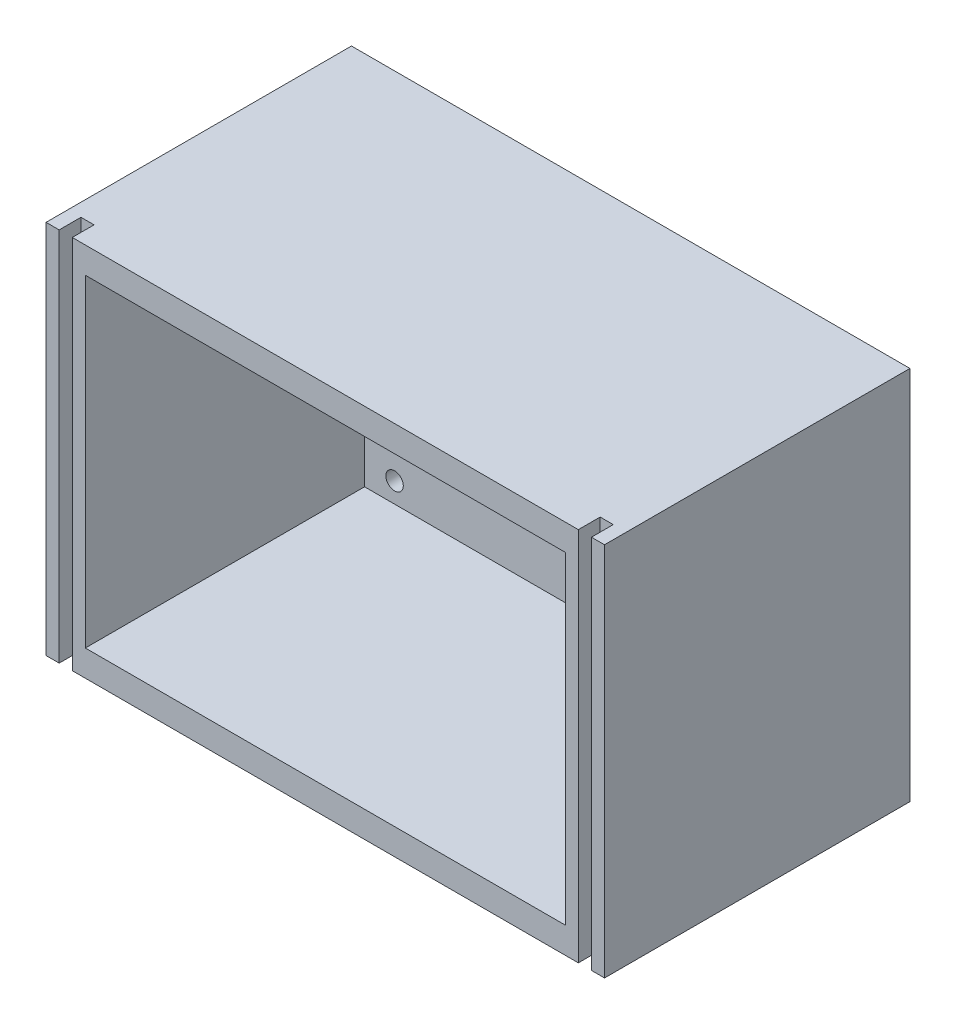
from build123d import *

# Parameters (mm, degrees)
SKETCH_1_W         = 3
SKETCH_1_H         = 86
EXTRUDE_10_DEPTH   = 70
SKETCH_1_W_2       = 116
SKETCH_1_W_3       = 110
SKETCH_1_H_2       = 74
EXTRUDE_10_2_DEPTH = 70
EXTRUDE_10_3_DEPTH = 70
EXTRUDE_11_DEPTH   = 65
SKETCH_1_12_W      = 110
SKETCH_1_12_H      = 74
SKETCH_1_12_R      = 2
EXTRUDE_12_DEPTH   = 6


with BuildPart() as part:
    # Эскиз1 → Бобышка-Вытянуть10 (new body)
    with BuildSketch(Plane.XY):
        with Locations((-60.077319588, 1.278350515)):
            Rectangle(SKETCH_1_W, SKETCH_1_H)
    extrude(amount=EXTRUDE_10_DEPTH)



with BuildPart() as body_2:
    # Эскиз1 → Extrude 10 2 (new body)
    with BuildSketch(Plane.XY):
        with Locations((2.422680412, 1.278350515)):
            Rectangle(SKETCH_1_W_2, SKETCH_1_H)
        with Locations((2.422680412, 1.278350515)):
            Rectangle(SKETCH_1_W_3, SKETCH_1_H_2, mode=Mode.SUBTRACT)
    extrude(amount=EXTRUDE_10_2_DEPTH)


with BuildPart() as body_3:
    # Эскиз1 → Extrude 10 3 (new body)
    with BuildSketch(Plane.XY):
        with Locations((64.922680412, 1.278350515)):
            Rectangle(SKETCH_1_W, SKETCH_1_H)
    extrude(amount=EXTRUDE_10_3_DEPTH)


with BuildPart() as part_1:
    add(part.part)

    add(body_2.part)  # Бобышка-Вытянуть11 merges body 2

    add(body_3.part)  # Бобышка-Вытянуть11 merges body 3
    # Эскиз1<11> → Бобышка-Вытянуть11 (add)
    with BuildSketch(Plane.XY):
        Polygon((-58.577319588, 38.278350515), (-58.577319588, 44.278350515), (-55.577319588, 44.278350515), (-55.577319588, 38.278350515), (-55.577319588, -35.721649485), (-55.577319588, -41.721649485), (-58.577319588, -41.721649485), (-58.577319588, -35.721649485), align=None)
        Polygon((60.422680412, -35.721649485), (60.422680412, -41.721649485), (63.422680412, -41.721649485), (63.422680412, -35.721649485), (63.422680412, 38.278350515), (63.422680412, 44.278350515), (60.422680412, 44.278350515), (60.422680412, 38.278350515), align=None)
    extrude(amount=EXTRUDE_11_DEPTH)

    # Эскиз1<12> → Бобышка-Вытянуть12 (add)
    with BuildSketch(Plane.XY):
        with Locations((2.422680412, 1.278350515)):
            Rectangle(SKETCH_1_12_W, SKETCH_1_12_H)
        with Locations((50.546562804, 33.65259867)):
            Circle(SKETCH_1_12_R, mode=Mode.SUBTRACT)
        with Locations((-45.701201979, 33.65259867)):
            Circle(SKETCH_1_12_R, mode=Mode.SUBTRACT)
        with Locations((50.546562804, -31.095897639)):
            Circle(SKETCH_1_12_R, mode=Mode.SUBTRACT)
        with Locations((50.546562804, -16.095897639)):
            Circle(SKETCH_1_12_R, mode=Mode.SUBTRACT)
        with Locations((50.546562804, 18.65259867)):
            Circle(SKETCH_1_12_R, mode=Mode.SUBTRACT)
        with Locations((-45.701201979, -16.095897639)):
            Circle(SKETCH_1_12_R, mode=Mode.SUBTRACT)
        with Locations((-45.701201979, 18.65259867)):
            Circle(SKETCH_1_12_R, mode=Mode.SUBTRACT)
        with Locations((-45.701201979, -31.095897639)):
            Circle(SKETCH_1_12_R, mode=Mode.SUBTRACT)
    extrude(amount=EXTRUDE_12_DEPTH)


solid = part_1.part
